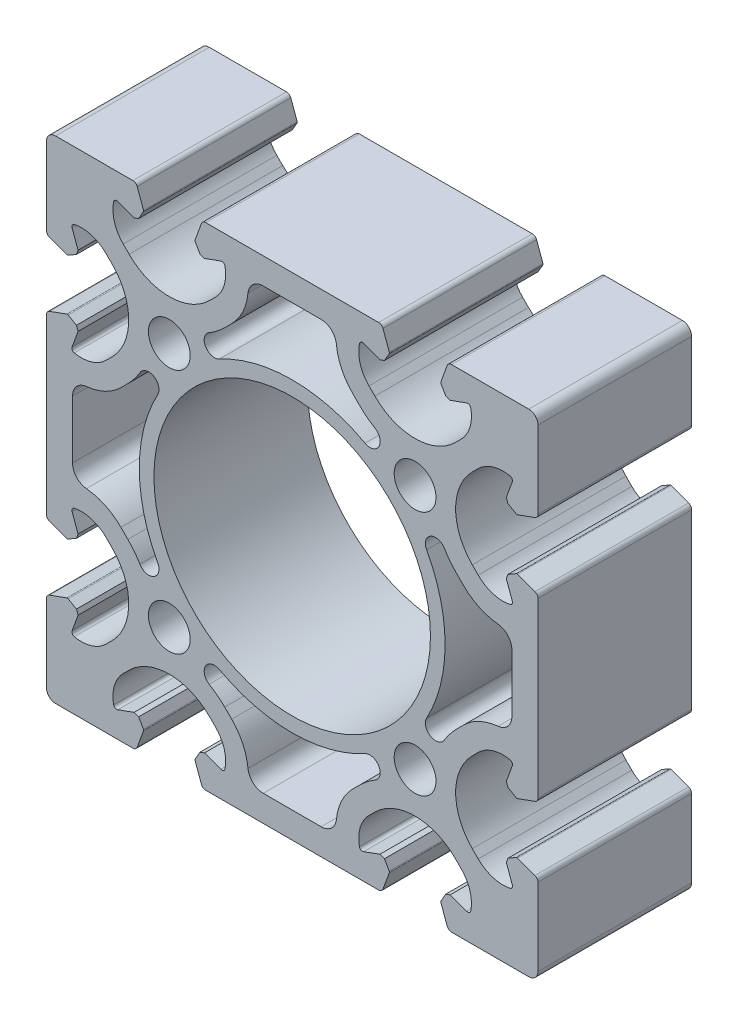
from build123d import *

# Parameters (mm, degrees)
SK_MAIN_EXTRUSION_R   = 3.4
SK_MAIN_EXTRUSION_R_2 = 22.5
MAIN_EXTRUSION_DEPTH  = 25


with BuildPart() as part:
    # Sk Main Extrusion → Main Extrusion (new body)
    with BuildSketch(Plane.XY):
        with BuildLine():
            Line((-36.671180212, -24.190076845), (-39.506515107, -25.222054351))
            ThreePointArc((-39.506515107, -25.222054351), (-39.864364033, -25.496641489), (-40, -25.926823816))
            Line((-40, -25.926823816), (-40, -38.5))
            ThreePointArc((-40, -38.5), (-39.560660172, -39.560660172), (-38.5, -40))
            Line((-38.5, -40), (-25.926823816, -40))
            ThreePointArc((-25.926823816, -40), (-25.496641489, -39.864364033), (-25.222054351, -39.506515107))
            Line((-25.222054351, -39.506515107), (-24.190076845, -36.671180212))
            ThreePointArc((-24.190076845, -36.671180212), (-24.175951325, -36.563886241), (-24.208493649, -36.460675177))
            Line((-24.208493649, -36.460675177), (-24.987558066, -35.111296024))
            Line((-24.987558066, -35.111296024), (-25.718509166, -34.845251581))
            Line((-25.718509166, -34.845251581), (-28.396186179, -35.81984631))
            ThreePointArc((-28.396186179, -35.81984631), (-28.811074612, -35.786489799), (-29.056960151, -35.450654467))
            ThreePointArc((-29.056960151, -35.450654467), (-28.933433013, -32.665882372), (-27.504160339, -30.272684887))
            Line((-27.504160339, -30.272684887), (-26.540737726, -29.309262274))
            ThreePointArc((-26.540737726, -29.309262274), (-20, -26.6), (-13.459262274, -29.309262274))
            Line((-13.459262274, -29.309262274), (-12.495839661, -30.272684887))
            ThreePointArc((-12.495839661, -30.272684887), (-11.066566987, -32.665882372), (-10.943039849, -35.450654467))
            ThreePointArc((-10.943039849, -35.450654467), (-11.188925388, -35.786489799), (-11.603813821, -35.81984631))
            Line((-11.603813821, -35.81984631), (-14.281490834, -34.845251581))
            Line((-14.281490834, -34.845251581), (-15.012441934, -35.111296024))
            Line((-15.012441934, -35.111296024), (-15.791506351, -36.460675177))
            ThreePointArc((-15.791506351, -36.460675177), (-15.824048675, -36.563886241), (-15.809923155, -36.671180212))
            Line((-15.809923155, -36.671180212), (-14.777945649, -39.506515107))
            ThreePointArc((-14.777945649, -39.506515107), (-14.503358511, -39.864364033), (-14.073176184, -40))
            Line((-14.073176184, -40), (14.073176184, -40))
            ThreePointArc((14.073176184, -40), (14.503358511, -39.864364033), (14.777945649, -39.506515107))
            Line((14.777945649, -39.506515107), (15.809923155, -36.671180212))
            ThreePointArc((15.809923155, -36.671180212), (15.824048675, -36.563886241), (15.791506351, -36.460675177))
            Line((15.791506351, -36.460675177), (15.012441934, -35.111296024))
            Line((15.012441934, -35.111296024), (14.281490834, -34.845251581))
            Line((14.281490834, -34.845251581), (11.603813821, -35.81984631))
            ThreePointArc((11.603813821, -35.81984631), (11.188925388, -35.786489799), (10.943039849, -35.450654467))
            ThreePointArc((10.943039849, -35.450654467), (11.066566987, -32.665882372), (12.495839661, -30.272684887))
            Line((12.495839661, -30.272684887), (13.459262274, -29.309262274))
            ThreePointArc((13.459262274, -29.309262274), (20, -26.6), (26.540737726, -29.309262274))
            Line((26.540737726, -29.309262274), (27.504160339, -30.272684887))
            ThreePointArc((27.504160339, -30.272684887), (28.933433013, -32.665882372), (29.056960151, -35.450654467))
            ThreePointArc((29.056960151, -35.450654467), (28.811074612, -35.786489799), (28.396186179, -35.81984631))
            Line((28.396186179, -35.81984631), (25.718509166, -34.845251581))
            Line((25.718509166, -34.845251581), (24.987558066, -35.111296024))
            Line((24.987558066, -35.111296024), (24.208493649, -36.460675177))
            ThreePointArc((24.208493649, -36.460675177), (24.175951325, -36.563886241), (24.190076845, -36.671180212))
            Line((24.190076845, -36.671180212), (25.222054351, -39.506515107))
            ThreePointArc((25.222054351, -39.506515107), (25.496641489, -39.864364033), (25.926823816, -40))
            Line((25.926823816, -40), (38.5, -40))
            ThreePointArc((38.5, -40), (39.560660172, -39.560660172), (40, -38.5))
            Line((40, -38.5), (40, -25.926823816))
            ThreePointArc((40, -25.926823816), (39.864364033, -25.496641489), (39.506515107, -25.222054351))
            Line((39.506515107, -25.222054351), (36.671180212, -24.190076845))
            ThreePointArc((36.671180212, -24.190076845), (36.563886241, -24.175951325), (36.460675177, -24.208493649))
            Line((36.460675177, -24.208493649), (35.111296024, -24.987558066))
            Line((35.111296024, -24.987558066), (34.845251581, -25.718509166))
            Line((34.845251581, -25.718509166), (35.81984631, -28.396186179))
            ThreePointArc((35.81984631, -28.396186179), (35.786489799, -28.811074612), (35.450654467, -29.056960151))
            ThreePointArc((35.450654467, -29.056960151), (32.665882372, -28.933433013), (30.272684887, -27.504160339))
            Line((30.272684887, -27.504160339), (29.309262274, -26.540737726))
            ThreePointArc((29.309262274, -26.540737726), (26.6, -20), (29.309262274, -13.459262274))
            Line((29.309262274, -13.459262274), (30.272684887, -12.495839661))
            ThreePointArc((30.272684887, -12.495839661), (32.665882372, -11.066566987), (35.450654467, -10.943039849))
            ThreePointArc((35.450654467, -10.943039849), (35.786489799, -11.188925388), (35.81984631, -11.603813821))
            Line((35.81984631, -11.603813821), (34.845251581, -14.281490834))
            Line((34.845251581, -14.281490834), (35.111296024, -15.012441934))
            Line((35.111296024, -15.012441934), (36.460675177, -15.791506351))
            ThreePointArc((36.460675177, -15.791506351), (36.563886241, -15.824048675), (36.671180212, -15.809923155))
            Line((36.671180212, -15.809923155), (39.506515107, -14.777945649))
            ThreePointArc((39.506515107, -14.777945649), (39.864364033, -14.503358511), (40, -14.073176184))
            Line((40, -14.073176184), (40, 14.073176184))
            ThreePointArc((40, 14.073176184), (39.864364033, 14.503358511), (39.506515107, 14.777945649))
            Line((39.506515107, 14.777945649), (36.671180212, 15.809923155))
            ThreePointArc((36.671180212, 15.809923155), (36.563886241, 15.824048675), (36.460675177, 15.791506351))
            Line((36.460675177, 15.791506351), (35.111296024, 15.012441934))
            Line((35.111296024, 15.012441934), (34.845251581, 14.281490834))
            Line((34.845251581, 14.281490834), (35.81984631, 11.603813821))
            ThreePointArc((35.81984631, 11.603813821), (35.786489799, 11.188925388), (35.450654467, 10.943039849))
            ThreePointArc((35.450654467, 10.943039849), (32.665882372, 11.066566987), (30.272684887, 12.495839661))
            Line((30.272684887, 12.495839661), (29.309262274, 13.459262274))
            ThreePointArc((29.309262274, 13.459262274), (26.6, 20), (29.309262274, 26.540737726))
            Line((29.309262274, 26.540737726), (30.272684887, 27.504160339))
            ThreePointArc((30.272684887, 27.504160339), (32.665882372, 28.933433013), (35.450654467, 29.056960151))
            ThreePointArc((35.450654467, 29.056960151), (35.786489799, 28.811074612), (35.81984631, 28.396186179))
            Line((35.81984631, 28.396186179), (34.845251581, 25.718509166))
            Line((34.845251581, 25.718509166), (35.111296024, 24.987558066))
            Line((35.111296024, 24.987558066), (36.460675177, 24.208493649))
            ThreePointArc((36.460675177, 24.208493649), (36.563886241, 24.175951325), (36.671180212, 24.190076845))
            Line((36.671180212, 24.190076845), (39.506515107, 25.222054351))
            ThreePointArc((39.506515107, 25.222054351), (39.864364033, 25.496641489), (40, 25.926823816))
            Line((40, 25.926823816), (40, 38.5))
            ThreePointArc((40, 38.5), (39.560660172, 39.560660172), (38.5, 40))
            Line((38.5, 40), (25.926823816, 40))
            ThreePointArc((25.926823816, 40), (25.496641489, 39.864364033), (25.222054351, 39.506515107))
            Line((25.222054351, 39.506515107), (24.190076845, 36.671180212))
            ThreePointArc((24.190076845, 36.671180212), (24.175951325, 36.563886241), (24.208493649, 36.460675177))
            Line((24.208493649, 36.460675177), (24.987558066, 35.111296024))
            Line((24.987558066, 35.111296024), (25.718509166, 34.845251581))
            Line((25.718509166, 34.845251581), (28.396186179, 35.81984631))
            ThreePointArc((28.396186179, 35.81984631), (28.811074612, 35.786489799), (29.056960151, 35.450654467))
            ThreePointArc((29.056960151, 35.450654467), (28.933433013, 32.665882372), (27.504160339, 30.272684887))
            Line((27.504160339, 30.272684887), (26.540737726, 29.309262274))
            ThreePointArc((26.540737726, 29.309262274), (20, 26.6), (13.459262274, 29.309262274))
            Line((13.459262274, 29.309262274), (12.495839661, 30.272684887))
            ThreePointArc((12.495839661, 30.272684887), (11.066566987, 32.665882372), (10.943039849, 35.450654467))
            ThreePointArc((10.943039849, 35.450654467), (11.188925388, 35.786489799), (11.603813821, 35.81984631))
            Line((11.603813821, 35.81984631), (14.281490834, 34.845251581))
            Line((14.281490834, 34.845251581), (15.012441934, 35.111296024))
            Line((15.012441934, 35.111296024), (15.791506351, 36.460675177))
            ThreePointArc((15.791506351, 36.460675177), (15.824048675, 36.563886241), (15.809923155, 36.671180212))
            Line((15.809923155, 36.671180212), (14.777945649, 39.506515107))
            ThreePointArc((14.777945649, 39.506515107), (14.503358511, 39.864364033), (14.073176184, 40))
            Line((14.073176184, 40), (-14.073176184, 40))
            ThreePointArc((-14.073176184, 40), (-14.503358511, 39.864364033), (-14.777945649, 39.506515107))
            Line((-14.777945649, 39.506515107), (-15.809923155, 36.671180212))
            ThreePointArc((-15.809923155, 36.671180212), (-15.824048675, 36.563886241), (-15.791506351, 36.460675177))
            Line((-15.791506351, 36.460675177), (-15.012441934, 35.111296024))
            Line((-15.012441934, 35.111296024), (-14.281490834, 34.845251581))
            Line((-14.281490834, 34.845251581), (-11.603813821, 35.81984631))
            ThreePointArc((-11.603813821, 35.81984631), (-11.188925388, 35.786489799), (-10.943039849, 35.450654467))
            ThreePointArc((-10.943039849, 35.450654467), (-11.066566987, 32.665882372), (-12.495839661, 30.272684887))
            Line((-12.495839661, 30.272684887), (-13.459262274, 29.309262274))
            ThreePointArc((-13.459262274, 29.309262274), (-20, 26.6), (-26.540737726, 29.309262274))
            Line((-26.540737726, 29.309262274), (-27.504160339, 30.272684887))
            ThreePointArc((-27.504160339, 30.272684887), (-28.933433013, 32.665882372), (-29.056960151, 35.450654467))
            ThreePointArc((-29.056960151, 35.450654467), (-28.811074612, 35.786489799), (-28.396186179, 35.81984631))
            Line((-28.396186179, 35.81984631), (-25.718509166, 34.845251581))
            Line((-25.718509166, 34.845251581), (-24.987558066, 35.111296024))
            Line((-24.987558066, 35.111296024), (-24.208493649, 36.460675177))
            ThreePointArc((-24.208493649, 36.460675177), (-24.175951325, 36.563886241), (-24.190076845, 36.671180212))
            Line((-24.190076845, 36.671180212), (-25.222054351, 39.506515107))
            ThreePointArc((-25.222054351, 39.506515107), (-25.496641489, 39.864364033), (-25.926823816, 40))
            Line((-25.926823816, 40), (-38.5, 40))
            ThreePointArc((-38.5, 40), (-39.560660172, 39.560660172), (-40, 38.5))
            Line((-40, 38.5), (-40, 25.926823816))
            ThreePointArc((-40, 25.926823816), (-39.864364033, 25.496641489), (-39.506515107, 25.222054351))
            Line((-39.506515107, 25.222054351), (-36.671180212, 24.190076845))
            ThreePointArc((-36.671180212, 24.190076845), (-36.563886241, 24.175951325), (-36.460675177, 24.208493649))
            Line((-36.460675177, 24.208493649), (-35.111296024, 24.987558066))
            Line((-35.111296024, 24.987558066), (-34.845251581, 25.718509166))
            Line((-34.845251581, 25.718509166), (-35.81984631, 28.396186179))
            ThreePointArc((-35.81984631, 28.396186179), (-35.786489799, 28.811074612), (-35.450654467, 29.056960151))
            ThreePointArc((-35.450654467, 29.056960151), (-32.665882372, 28.933433013), (-30.272684887, 27.504160339))
            Line((-30.272684887, 27.504160339), (-29.309262274, 26.540737726))
            ThreePointArc((-29.309262274, 26.540737726), (-26.6, 20), (-29.309262274, 13.459262274))
            Line((-29.309262274, 13.459262274), (-30.272684887, 12.495839661))
            ThreePointArc((-30.272684887, 12.495839661), (-32.665882372, 11.066566987), (-35.450654467, 10.943039849))
            ThreePointArc((-35.450654467, 10.943039849), (-35.786489799, 11.188925388), (-35.81984631, 11.603813821))
            Line((-35.81984631, 11.603813821), (-34.845251581, 14.281490834))
            Line((-34.845251581, 14.281490834), (-35.111296024, 15.012441934))
            Line((-35.111296024, 15.012441934), (-36.460675177, 15.791506351))
            ThreePointArc((-36.460675177, 15.791506351), (-36.563886241, 15.824048675), (-36.671180212, 15.809923155))
            Line((-36.671180212, 15.809923155), (-39.506515107, 14.777945649))
            ThreePointArc((-39.506515107, 14.777945649), (-39.864364033, 14.503358511), (-40, 14.073176184))
            Line((-40, 14.073176184), (-40, -14.073176184))
            ThreePointArc((-40, -14.073176184), (-39.864364033, -14.503358511), (-39.506515107, -14.777945649))
            Line((-39.506515107, -14.777945649), (-36.671180212, -15.809923155))
            ThreePointArc((-36.671180212, -15.809923155), (-36.563886241, -15.824048675), (-36.460675177, -15.791506351))
            Line((-36.460675177, -15.791506351), (-35.111296024, -15.012441934))
            Line((-35.111296024, -15.012441934), (-34.845251581, -14.281490834))
            Line((-34.845251581, -14.281490834), (-35.81984631, -11.603813821))
            ThreePointArc((-35.81984631, -11.603813821), (-35.786489799, -11.188925388), (-35.450654467, -10.943039849))
            ThreePointArc((-35.450654467, -10.943039849), (-32.665882372, -11.066566987), (-30.272684887, -12.495839661))
            Line((-30.272684887, -12.495839661), (-29.309262274, -13.459262274))
            ThreePointArc((-29.309262274, -13.459262274), (-26.6, -20), (-29.309262274, -26.540737726))
            Line((-29.309262274, -26.540737726), (-30.272684887, -27.504160339))
            ThreePointArc((-30.272684887, -27.504160339), (-32.665882372, -28.933433013), (-35.450654467, -29.056960151))
            ThreePointArc((-35.450654467, -29.056960151), (-35.786489799, -28.811074612), (-35.81984631, -28.396186179))
            Line((-35.81984631, -28.396186179), (-34.845251581, -25.718509166))
            Line((-34.845251581, -25.718509166), (-35.111296024, -24.987558066))
            Line((-35.111296024, -24.987558066), (-36.460675177, -24.208493649))
            ThreePointArc((-36.460675177, -24.208493649), (-36.563886241, -24.175951325), (-36.671180212, -24.190076845))
        make_face()
        with Locations((20, -20)):
            Circle(SK_MAIN_EXTRUSION_R, mode=Mode.SUBTRACT)
        with Locations((-20, -20)):
            Circle(SK_MAIN_EXTRUSION_R, mode=Mode.SUBTRACT)
        with Locations((-20, 20)):
            Circle(SK_MAIN_EXTRUSION_R, mode=Mode.SUBTRACT)
        with Locations((20, 20)):
            Circle(SK_MAIN_EXTRUSION_R, mode=Mode.SUBTRACT)
        Circle(SK_MAIN_EXTRUSION_R_2, mode=Mode.SUBTRACT)
        with BuildLine():
            Line((10.98438854, 26.73438854), (9.84861063, 27.87016645))
            ThreePointArc((9.84861063, 27.87016645), (8.033705637, 30.449632649), (7.196663062, 33.490501888))
            ThreePointArc((7.196663062, 33.490501888), (6.388845176, 35.10084504), (4.708258183, 35.75))
            Line((4.708258183, 35.75), (-4.708258183, 35.75))
            ThreePointArc((-4.708258183, 35.75), (-6.388845176, 35.10084504), (-7.196663062, 33.490501888))
            ThreePointArc((-7.196663062, 33.490501888), (-8.033705637, 30.449632649), (-9.84861063, 27.87016645))
            Line((-9.84861063, 27.87016645), (-10.98438854, 26.73438854))
            ThreePointArc((-10.98438854, 26.73438854), (-12.183791531, 25.676798664), (-13.506141353, 24.777657503))
            ThreePointArc((-13.506141353, 24.777657503), (-14.107813799, 22.519441768), (-11.861291076, 21.875482384))
            ThreePointArc((-11.861291076, 21.875482384), (0, 24.884271247), (11.861291076, 21.875482384))
            ThreePointArc((11.861291076, 21.875482384), (14.107813799, 22.519441768), (13.506141353, 24.777657503))
            ThreePointArc((13.506141353, 24.777657503), (12.183791531, 25.676798664), (10.98438854, 26.73438854))
        make_face(mode=Mode.SUBTRACT)
        with BuildLine():
            Line((-35.75, 4.708258183), (-35.75, -4.708258183))
            ThreePointArc((-35.75, -4.708258183), (-35.10084504, -6.388845176), (-33.490501888, -7.196663062))
            ThreePointArc((-33.490501888, -7.196663062), (-30.449632649, -8.033705637), (-27.87016645, -9.84861063))
            Line((-27.87016645, -9.84861063), (-26.73438854, -10.98438854))
            ThreePointArc((-26.73438854, -10.98438854), (-25.676798664, -12.183791531), (-24.777657503, -13.506141353))
            ThreePointArc((-24.777657503, -13.506141353), (-22.519441768, -14.107813799), (-21.875482384, -11.861291076))
            ThreePointArc((-21.875482384, -11.861291076), (-24.884271247, 0), (-21.875482384, 11.861291076))
            ThreePointArc((-21.875482384, 11.861291076), (-22.519441768, 14.107813799), (-24.777657503, 13.506141353))
            ThreePointArc((-24.777657503, 13.506141353), (-25.676798664, 12.183791531), (-26.73438854, 10.98438854))
            Line((-26.73438854, 10.98438854), (-27.87016645, 9.84861063))
            ThreePointArc((-27.87016645, 9.84861063), (-30.449632649, 8.033705637), (-33.490501888, 7.196663062))
            ThreePointArc((-33.490501888, 7.196663062), (-35.10084504, 6.388845176), (-35.75, 4.708258183))
        make_face(mode=Mode.SUBTRACT)
        with BuildLine():
            Line((26.73438854, -10.98438854), (27.87016645, -9.84861063))
            ThreePointArc((27.87016645, -9.84861063), (30.449632649, -8.033705637), (33.490501888, -7.196663062))
            ThreePointArc((33.490501888, -7.196663062), (35.10084504, -6.388845176), (35.75, -4.708258183))
            Line((35.75, -4.708258183), (35.75, 4.708258183))
            ThreePointArc((35.75, 4.708258183), (35.10084504, 6.388845176), (33.490501888, 7.196663062))
            ThreePointArc((33.490501888, 7.196663062), (30.449632649, 8.033705637), (27.87016645, 9.84861063))
            Line((27.87016645, 9.84861063), (26.73438854, 10.98438854))
            ThreePointArc((26.73438854, 10.98438854), (25.676798664, 12.183791531), (24.777657503, 13.506141353))
            ThreePointArc((24.777657503, 13.506141353), (22.519441768, 14.107813799), (21.875482384, 11.861291076))
            ThreePointArc((21.875482384, 11.861291076), (24.884271247, 0), (21.875482384, -11.861291076))
            ThreePointArc((21.875482384, -11.861291076), (22.519441768, -14.107813799), (24.777657503, -13.506141353))
            ThreePointArc((24.777657503, -13.506141353), (25.676798664, -12.183791531), (26.73438854, -10.98438854))
        make_face(mode=Mode.SUBTRACT)
        with BuildLine():
            Line((-10.98438854, -26.73438854), (-9.84861063, -27.87016645))
            ThreePointArc((-9.84861063, -27.87016645), (-8.033705637, -30.449632649), (-7.196663062, -33.490501888))
            ThreePointArc((-7.196663062, -33.490501888), (-6.388845176, -35.10084504), (-4.708258183, -35.75))
            Line((-4.708258183, -35.75), (4.708258183, -35.75))
            ThreePointArc((4.708258183, -35.75), (6.388845176, -35.10084504), (7.196663062, -33.490501888))
            ThreePointArc((7.196663062, -33.490501888), (8.033705637, -30.449632649), (9.84861063, -27.87016645))
            Line((9.84861063, -27.87016645), (10.98438854, -26.73438854))
            ThreePointArc((10.98438854, -26.73438854), (12.183791531, -25.676798664), (13.506141353, -24.777657503))
            ThreePointArc((13.506141353, -24.777657503), (14.107813799, -22.519441768), (11.861291076, -21.875482384))
            ThreePointArc((11.861291076, -21.875482384), (0, -24.884271247), (-11.861291076, -21.875482384))
            ThreePointArc((-11.861291076, -21.875482384), (-14.107813799, -22.519441768), (-13.506141353, -24.777657503))
            ThreePointArc((-13.506141353, -24.777657503), (-12.183791531, -25.676798664), (-10.98438854, -26.73438854))
        make_face(mode=Mode.SUBTRACT)
    extrude(amount=-MAIN_EXTRUSION_DEPTH)


solid = part.part
